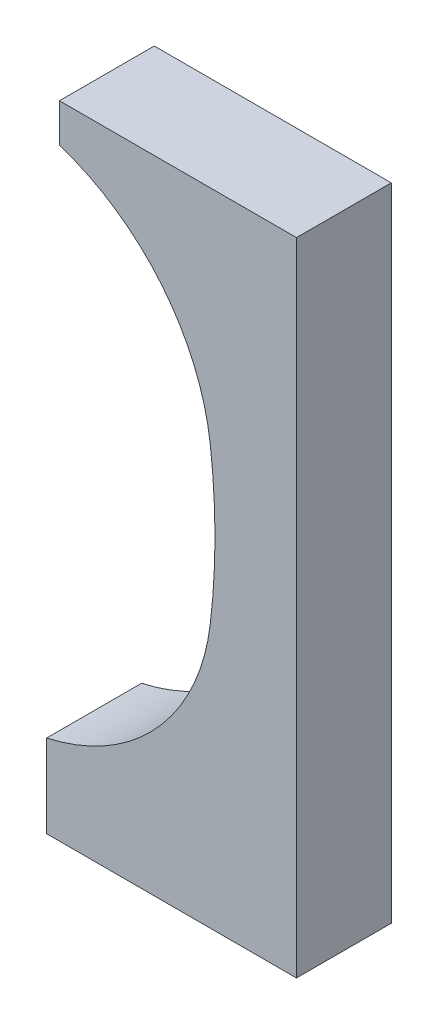
from build123d import *

# Parameters (mm, degrees)
EXTRUDE_4_DEPTH = 32


with BuildPart() as part:
    # Эскиз1 → Бобышка-Вытянуть4 (new body)
    with BuildSketch(Plane.XY):
        with BuildLine():
            Line((4.299618531, 175.402841826), (4.299618531, 188.402841826))
            Line((4.299618531, 188.402841826), (84.299618531, 188.402841826))
            Line((84.299618531, 188.402841826), (84.299618531, 175.402841826))
            Line((84.299618531, 175.402841826), (84.299618531, 0))
            Line((84.299618531, 0), (84.299618531, -28))
            Line((84.299618531, -28), (0, -28))
            Line((0, -28), (0, 0))
            ThreePointArc((0, 0), (37.229295141, 21.561020186), (55.173142182, 60.662380285))
            ThreePointArc((55.173142182, 60.662380285), (56.797307883, 87.162380285), (55.173142182, 113.662380285))
            ThreePointArc((55.173142182, 113.662380285), (38.726552267, 151.940422917), (4.299618531, 175.402841826))
        make_face()
    extrude(amount=EXTRUDE_4_DEPTH)


solid = part.part
